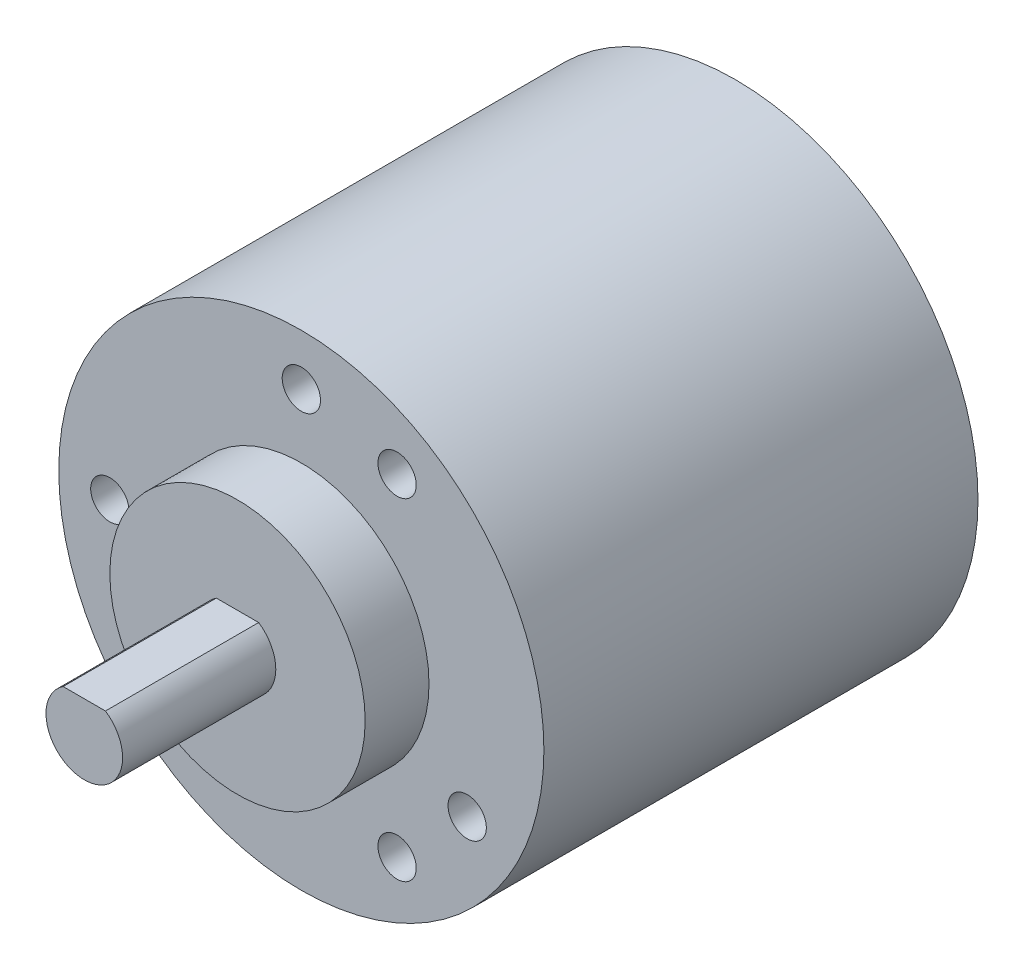
from build123d import *

# Parameters (mm, degrees)
SKETCH1_R           = 19
BOSS_EXTRUDE1_DEPTH = 34
SKETCH2_R           = 1.5
CUT_EXTRUDE1_DEPTH  = 6
SKETCH3_R           = 10
BOSS_EXTRUDE2_DEPTH = 5
BOSS_EXTRUDE3_DEPTH = 12


with BuildPart() as part:
    # Sketch1 → Boss-Extrude1 (new body)
    with BuildSketch(Plane.XY):
        Circle(SKETCH1_R)
    extrude(amount=BOSS_EXTRUDE1_DEPTH)

    # Sketch2 → Cut-Extrude1 (cut)
    with BuildSketch(Plane.XY.offset(34)):
        with Locations((-12.990381057, -7.5)):
            Circle(SKETCH2_R)
        with Locations((-15, 0)):
            Circle(SKETCH2_R)
        with Locations((0, 15)):
            Circle(SKETCH2_R)
        with Locations((7.5, 12.990381057)):
            Circle(SKETCH2_R)
        with Locations((12.990381057, -7.5)):
            Circle(SKETCH2_R)
        with Locations((7.5, -12.990381057)):
            Circle(SKETCH2_R)
    extrude(amount=-CUT_EXTRUDE1_DEPTH, mode=Mode.SUBTRACT)

    # Sketch3 → Boss-Extrude2 (add)
    with BuildSketch(Plane.XY.offset(34)):
        Circle(SKETCH3_R)
    extrude(amount=BOSS_EXTRUDE2_DEPTH)

    # Sketch4 → Boss-Extrude3 (add)
    with BuildSketch(Plane.XY.offset(39)):
        with BuildLine():
            ThreePointArc((3, 0), (2.643382037, 1.418637165), (1.658312395, 2.5))
            Line((1.658312395, 2.5), (-1.658312395, 2.5))
            ThreePointArc((-1.658312395, 2.5), (-1.418637165, -2.643382037), (3, 0))
        make_face()
    extrude(amount=BOSS_EXTRUDE3_DEPTH)


solid = part.part
